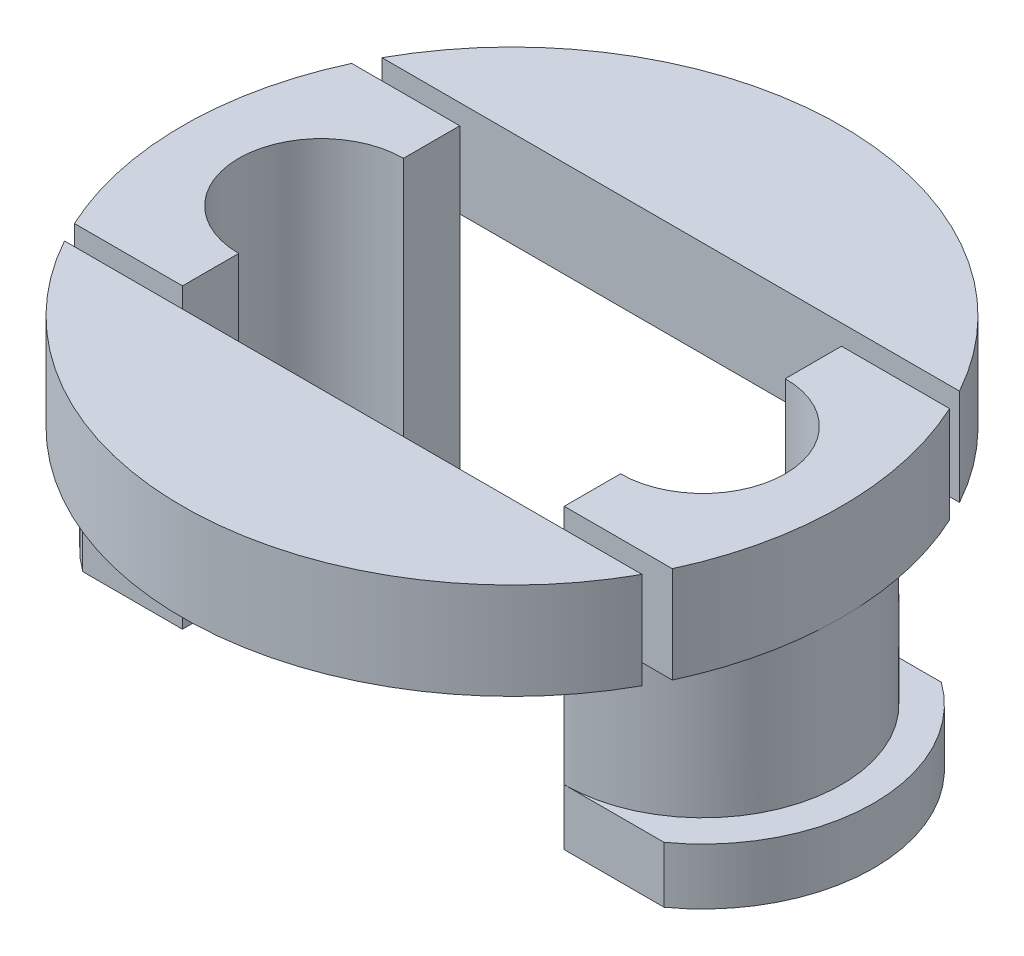
from build123d import *

# Parameters (mm, degrees)
EXTRUDE_1_DEPTH     = 4
SKETCH_2_R          = 8.2
EXTRUDE_2_DEPTH     = 2.4
EXTRUDE_3_DEPTH     = 1
EXTRUDE_4_DEPTH     = 1.4
CUT_EXTRUDE_1_DEPTH = 7.4
SKETCH_13_W         = 8.5
SKETCH_13_H         = 1.9
CUT_EXTRUDE_2_DEPTH = 7.4


with BuildPart() as part:
    # ｽｹｯﾁ1 → ﾎﾞｽ - 押し出し1 (new body)
    with BuildSketch(Plane(origin=(0, 0, 0), x_dir=(1, 0, 0), z_dir=(0, 1, 0))):
        with BuildLine():
            Line((-5.6, 3.45), (3.9, 3.45))
            ThreePointArc((3.9, 3.45), (7.35, 0), (3.9, -3.45))
            Line((3.9, -3.45), (-5.6, -3.45))
            ThreePointArc((-5.6, -3.45), (-9.05, 0), (-5.6, 3.45))
        make_face()
        with BuildLine():
            Line((-5.6, 2.05), (3.9, 2.05))
            ThreePointArc((3.9, 2.05), (5.95, 0), (3.9, -2.05))
            Line((3.9, -2.05), (-5.6, -2.05))
            ThreePointArc((-5.6, -2.05), (-7.65, 0), (-5.6, 2.05))
        make_face(mode=Mode.SUBTRACT)
    extrude(amount=EXTRUDE_1_DEPTH)

    # ｽｹｯﾁ2 → ﾎﾞｽ - 押し出し2 (add)
    with BuildSketch(Plane(origin=(0, 4, 0), x_dir=(1, 0, 0), z_dir=(0, 1, 0))):
        with Locations((-0.85, 0)):
            Circle(SKETCH_2_R)
        with BuildLine():
            Line((-5.6, -2.05), (3.9, -2.05))
            ThreePointArc((3.9, -2.05), (5.95, 0), (3.9, 2.05))
            Line((3.9, 2.05), (-5.6, 2.05))
            ThreePointArc((-5.6, 2.05), (-7.65, 0), (-5.6, -2.05))
        make_face(mode=Mode.SUBTRACT)
    extrude(amount=EXTRUDE_2_DEPTH)

    # ｽｹｯﾁ3 → ﾎﾞｽ - 押し出し3 (add)
    with BuildSketch(Plane.XZ):
        with BuildLine():
            Line((-5.6, -3.45), (3.9, -3.45))
            ThreePointArc((3.9, -3.45), (7.35, 0), (3.9, 3.45))
            Line((3.9, 3.45), (-5.6, 3.45))
            ThreePointArc((-5.6, 3.45), (-9.05, 0), (-5.6, -3.45))
        make_face()
        with BuildLine():
            Line((-5.6, 2.05), (3.9, 2.05))
            ThreePointArc((3.9, 2.05), (5.95, 0), (3.9, -2.05))
            Line((3.9, -2.05), (-5.6, -2.05))
            ThreePointArc((-5.6, -2.05), (-7.65, 0), (-5.6, 2.05))
        make_face(mode=Mode.SUBTRACT)
    extrude(amount=EXTRUDE_3_DEPTH)

    # ｽｹｯﾁ4 → ﾎﾞｽ - 押し出し4 (add)
    with BuildSketch(Plane.XZ.offset(1)):
        with BuildLine():
            Line((3.9, -3.45), (6.381934729, -3.45))
            ThreePointArc((6.381934729, -3.45), (8.15, 0), (6.381934729, 3.45))
            Line((6.381934729, 3.45), (3.9, 3.45))
            ThreePointArc((3.9, 3.45), (7.35, 0), (3.9, -3.45))
        make_face()
        with BuildLine():
            Line((-5.6, 3.45), (-8.081934729, 3.45))
            ThreePointArc((-8.081934729, 3.45), (-9.85, 0), (-8.081934729, -3.45))
            Line((-8.081934729, -3.45), (-5.6, -3.45))
            ThreePointArc((-5.6, -3.45), (-9.05, 0), (-5.6, 3.45))
        make_face()
    extrude(amount=-EXTRUDE_4_DEPTH)

    # ｽｹｯﾁ12 → ｶｯﾄ - 押し出し1 (cut)
    with BuildSketch(Plane.XZ.offset(1)):
        Polygon((-5.1, 3.95), (-5.1, -3.95), (-14.4591774, -3.95), (-14.4591774, -3.45), (-5.6, -3.45), (-5.6, 3.45), (-14.4591774, 3.45), (-14.4591774, 3.95), align=None)
        Polygon((12.7591774, 3.45), (12.7591774, 3.95), (3.4, 3.95), (3.4, -3.95), (12.7591774, -3.95), (12.7591774, -3.45), (3.9, -3.45), (3.9, 3.45), align=None)
    extrude(amount=-CUT_EXTRUDE_1_DEPTH, mode=Mode.SUBTRACT)

    # ｽｹｯﾁ13 → ｶｯﾄ - 押し出し2 (cut)
    with BuildSketch(Plane.XZ.offset(1)):
        with Locations((-0.85, 3)):
            Rectangle(SKETCH_13_W, SKETCH_13_H)
        with Locations((-0.85, -3)):
            Rectangle(SKETCH_13_W, SKETCH_13_H)
    extrude(amount=-CUT_EXTRUDE_2_DEPTH, mode=Mode.SUBTRACT)


solid = part.part
